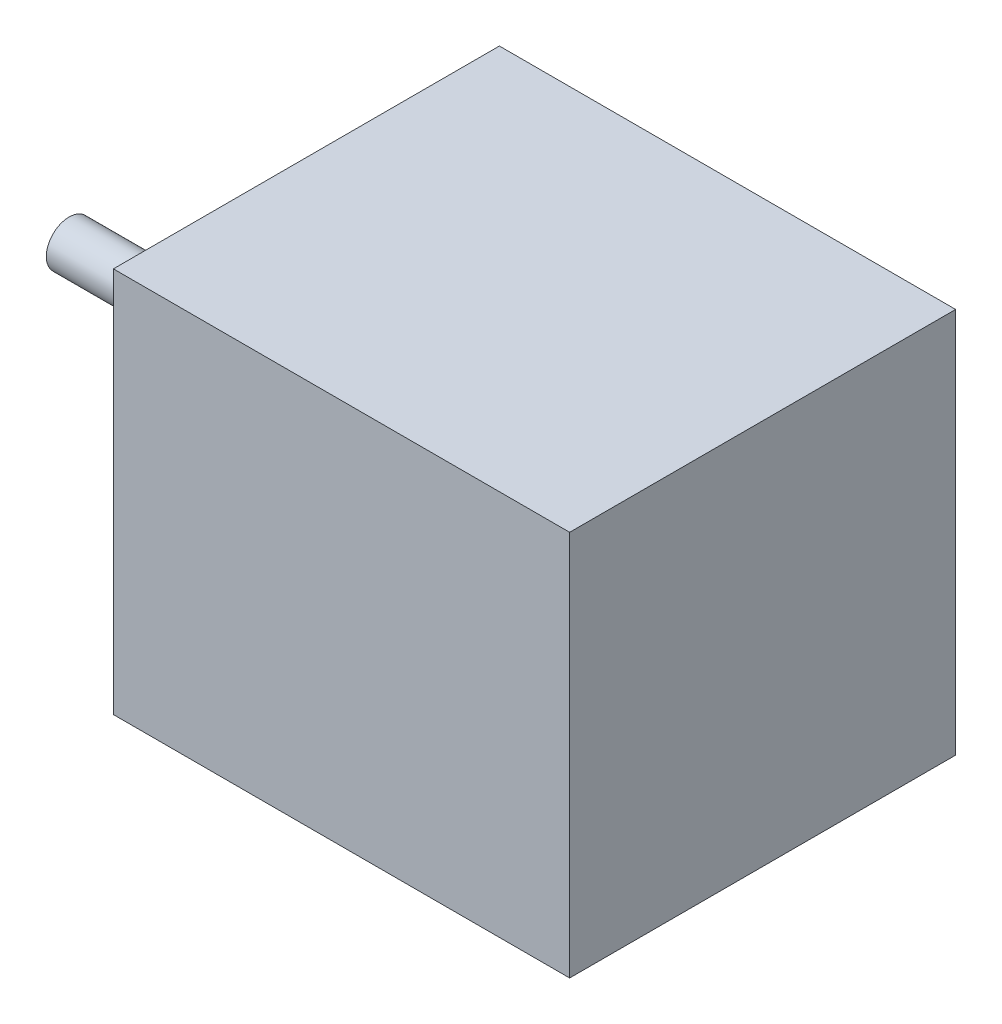
from build123d import *

# Parameters (mm, degrees)
SKETCH1_W           = 42.3
SKETCH1_H           = 42.3
BOSS_EXTRUDE1_DEPTH = 50
SKETCH2_R           = 11
BOSS_EXTRUDE2_DEPTH = 2
BOSS_EXTRUDE3_START = -2
SKETCH3_R           = 2.5
BOSS_EXTRUDE3_DEPTH = 24
SKETCH4_R           = 2
CUT_EXTRUDE1_DEPTH  = 4.5


with BuildPart() as part:
    # Sketch1 → Boss-Extrude1 (new body)
    with BuildSketch(Plane(origin=(0, 0, 0), x_dir=(0, 0, -1), z_dir=(1, 0, 0))):
        Rectangle(SKETCH1_W, SKETCH1_H)
    extrude(amount=BOSS_EXTRUDE1_DEPTH)

    # Sketch2 → Boss-Extrude2 (add)
    with BuildSketch(Plane(origin=(0, 0, 0), x_dir=(0, 0, -1), z_dir=(1, 0, 0))):
        Circle(SKETCH2_R)
    extrude(amount=-BOSS_EXTRUDE2_DEPTH)

    # Sketch3 → Boss-Extrude3 (add)
    with BuildSketch(Plane(origin=(0, 0, 0), x_dir=(0, 0, -1), z_dir=(1, 0, 0)).offset(BOSS_EXTRUDE3_START)):
        Circle(SKETCH3_R)
    extrude(amount=-BOSS_EXTRUDE3_DEPTH)

    # Sketch4 → Cut-Extrude1 (cut)
    with BuildSketch(Plane(origin=(0, 0, 0), x_dir=(0, 0, -1), z_dir=(1, 0, 0))):
        with Locations((15.5, 16.5)):
            Circle(SKETCH4_R)
        with Locations((15.5, -16.5)):
            Circle(SKETCH4_R)
        with Locations((-15.5, -16.5)):
            Circle(SKETCH4_R)
        with Locations((-15.5, 16.5)):
            Circle(SKETCH4_R)
    extrude(amount=CUT_EXTRUDE1_DEPTH, mode=Mode.SUBTRACT)


solid = part.part
